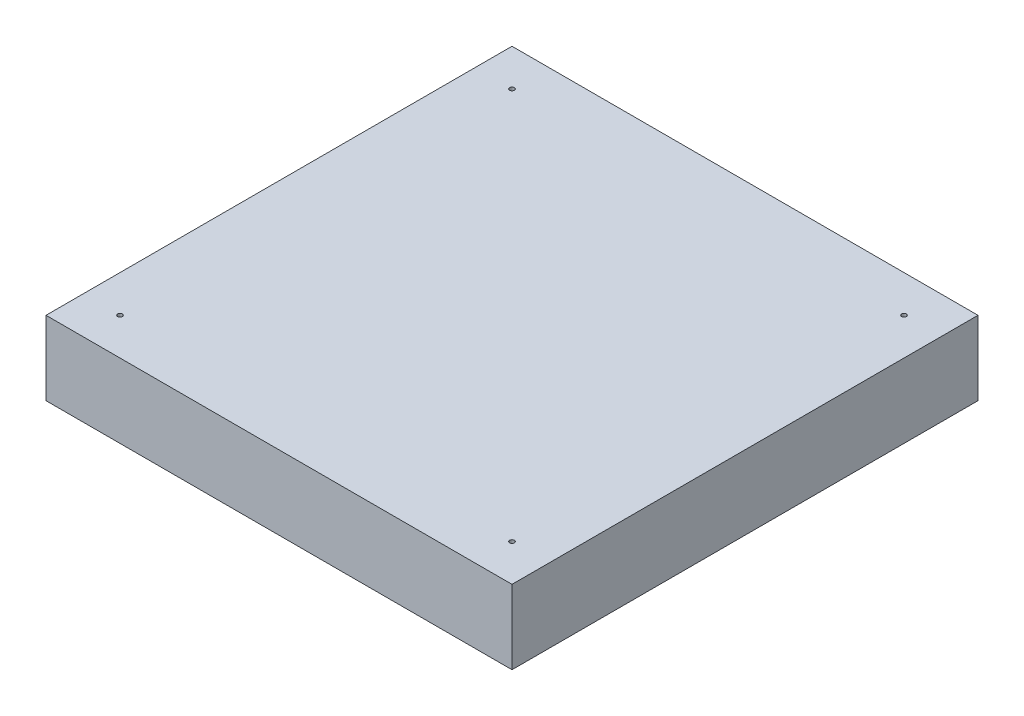
from build123d import *

# Parameters (mm, degrees)
SKETCH1_W                                   = 160
SKETCH1_H                                   = 160
BOSS_EXTRUDE1_DEPTH                         = 25.4
CBORE_FOR_0_BINDING_HEAD_MACHINE_SC_2_COUNT = 2
CBORE_FOR_0_BINDING_HEAD_MACHINE_SC_2_PITCH = 134.6
CBORE_FOR_0_BINDING_HEAD_MACHINE_SC_3_COUNT = 2
CBORE_FOR_0_BINDING_HEAD_MACHINE_SC_3_PITCH = 190.353145495
CBORE_FOR_0_BINDING_HEAD_MACHINE_SC_4_COUNT = 2
CBORE_FOR_0_BINDING_HEAD_MACHINE_SC_4_PITCH = 134.6


with BuildPart() as part:
    # Sketch1 → Boss-Extrude1 (new body)
    with BuildSketch(Plane(origin=(0, 0, 0), x_dir=(1, 0, 0), z_dir=(0, 1, 0))):
        Rectangle(SKETCH1_W, SKETCH1_H)
    extrude(amount=BOSS_EXTRUDE1_DEPTH)

    # Sketch3 → CBORE for _0 Binding Head Machine Screw1 (revolve, cut)
    with BuildSketch(Plane(origin=(-67.3, 0, -67.3), x_dir=(0, 0, -1), z_dir=(1, 0, 0))):
        Polygon((0, 0), (0, 25.4), (0.80645, 25.4), (0.80645, 0.8128), (1.98501, 0.8128), (1.98501, 0.87249), (2.8575, 0), align=None)
    cbore_for_0_binding_head_machine_screw1 = revolve(axis=Axis((-67.3, -6.35, -67.3), (0, 1, 0)), mode=Mode.SUBTRACT)

    # CBORE for _0 Binding Head Machine Sc 2: CBORE for _0 Binding Head Machine Screw1 ×2
    with Locations(*[(i * CBORE_FOR_0_BINDING_HEAD_MACHINE_SC_2_PITCH, 0, 0) for i in range(1, CBORE_FOR_0_BINDING_HEAD_MACHINE_SC_2_COUNT)]):
        add(cbore_for_0_binding_head_machine_screw1, mode=Mode.SUBTRACT)

    # CBORE for _0 Binding Head Machine Sc 3: CBORE for _0 Binding Head Machine Screw1 ×2
    with Locations(*[Vector(0.7071067811865475, 0, 0.7071067811865476) * (i * CBORE_FOR_0_BINDING_HEAD_MACHINE_SC_3_PITCH) for i in range(1, CBORE_FOR_0_BINDING_HEAD_MACHINE_SC_3_COUNT)]):
        add(cbore_for_0_binding_head_machine_screw1, mode=Mode.SUBTRACT)

    # CBORE for _0 Binding Head Machine Sc 4: CBORE for _0 Binding Head Machine Screw1 ×2
    with Locations(*[(0, 0, i * CBORE_FOR_0_BINDING_HEAD_MACHINE_SC_4_PITCH) for i in range(1, CBORE_FOR_0_BINDING_HEAD_MACHINE_SC_4_COUNT)]):
        add(cbore_for_0_binding_head_machine_screw1, mode=Mode.SUBTRACT)


solid = part.part
